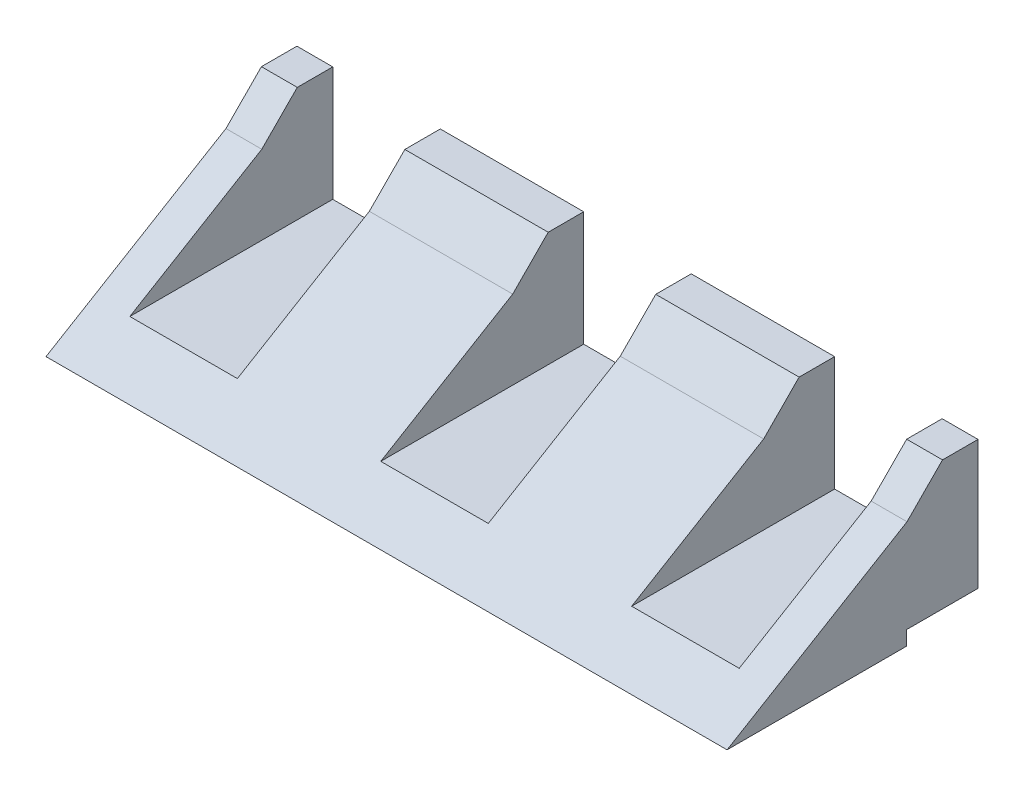
from build123d import *

# Parameters (mm, degrees)
CROQUIS1_W              = 100
CROQUIS1_H              = 85
SALIENTE_EXTRUIR1_DEPTH = 20
CORTAR_EXTRUIR1_REACH   = 102
CORTAR_EXTRUIR2_REACH   = 102
CORTAR_EXTRUIR6_DEPTH   = 5
CROQUIS11_W             = 15
CROQUIS11_H             = 16
CORTAR_EXTRUIR7_DEPTH   = 44
CROQUIS12_W             = 5
CROQUIS12_H             = 49.877192982
CORTAR_EXTRUIR8_DEPTH   = 44
CORTAR_EXTRUIR9_REACH   = 97
CROQUIS13_W             = 50
CROQUIS13_H             = 18
CROQUIS14_W             = 9.804862201
CROQUIS14_H             = 2
CORTAR_EXTRUIR10_DEPTH  = 121
CORTAR_EXTRUIR11_REACH  = 97
CORTAR_EXTRUIR12_REACH  = 97
CORTAR_EXTRUIR13_DEPTH  = 96


with BuildPart() as part:
    # Croquis1 → Saliente-Extruir1 (new body)
    with BuildSketch(Plane(origin=(0, 0, 0), x_dir=(1, 0, 0), z_dir=(0, 1, 0))):
        with Locations((-9.795321637, 18.377192982)):
            Rectangle(CROQUIS1_W, CROQUIS1_H)
    extrude(amount=SALIENTE_EXTRUIR1_DEPTH)

    # Croquis3 → Cortar-Extruir1 (cut, up to next)
    with BuildSketch(Plane(origin=(40.204678363, 0, 0), x_dir=(0, 0, -1), z_dir=(1, 0, 0)), mode=Mode.PRIVATE) as cortar_extruir1_sk1:
        Polygon((-24.122807018, 0), (0.976475977, 20), (-24.122807018, 20), align=None)
    cortar_extruir1_tool1 = extrude(cortar_extruir1_sk1.sketch, amount=-CORTAR_EXTRUIR1_REACH, mode=Mode.PRIVATE) & part.part
    add(cortar_extruir1_tool1.solids().sort_by_distance((40.204678, 13.333333, 15.756379))[0], mode=Mode.SUBTRACT)

    # Croquis4 → Cortar-Extruir2 (cut, up to next)
    with BuildSketch(Plane(origin=(40.204678363, 0, 0), x_dir=(0, 0, -1), z_dir=(1, 0, 0)), mode=Mode.PRIVATE) as cortar_extruir2_sk1:
        Polygon((0.976475977, 20), (0.976475977, 15), (-24.122807018, 0), align=None)
    cortar_extruir2_tool1 = extrude(cortar_extruir2_sk1.sketch, amount=-CORTAR_EXTRUIR2_REACH, mode=Mode.PRIVATE) & part.part
    add(cortar_extruir2_tool1.solids().sort_by_distance((40.204678, 11.666667, 7.389952))[0], mode=Mode.SUBTRACT)

    # Croquis8 → Cortar-Extruir6 (cut)
    with BuildSketch(Plane.ZY.offset(59.795321637)):
        Polygon((-11, 20), (-0.976475977, 20), (-0.976475977, 15), (24.122807018, 0), (-11, 0), align=None)
    extrude(amount=-CORTAR_EXTRUIR6_DEPTH, mode=Mode.SUBTRACT)

    # Croquis11 → Cortar-Extruir7 (cut)
    with BuildSketch(Plane.XY.offset(-11)):
        with Locations((27.704678363, 12)):
            Rectangle(CROQUIS11_W, CROQUIS11_H)
        Polygon((0.204678363, 20), (-14.795321637, 20), (-14.795321637, 4), (0.204678363, 4), (0.204678363, 18.881828366), align=None)
        with Locations((-42.295321637, 12)):
            Rectangle(CROQUIS11_W, CROQUIS11_H)
    extrude(amount=CORTAR_EXTRUIR7_DEPTH, mode=Mode.SUBTRACT)

    # Croquis12 → Cortar-Extruir8 (cut)
    with BuildSketch(Plane(origin=(0, 20, 0), x_dir=(1, 0, 0), z_dir=(0, 1, 0))):
        with Locations((-57.295321637, 35.938596491)):
            Rectangle(CROQUIS12_W, CROQUIS12_H)
    extrude(amount=-CORTAR_EXTRUIR8_DEPTH, mode=Mode.SUBTRACT)

    # Croquis13 → Cortar-Extruir9 (cut, up to next)
    with BuildSketch(Plane(origin=(40.204678363, 0, 0), x_dir=(0, 0, -1), z_dir=(1, 0, 0)), mode=Mode.PRIVATE) as cortar_extruir9_sk1:
        with Locations((35.877192982, 11)):
            Rectangle(CROQUIS13_W, CROQUIS13_H)
    cortar_extruir9_tool1 = extrude(cortar_extruir9_sk1.sketch, amount=-CORTAR_EXTRUIR9_REACH, mode=Mode.PRIVATE) & part.part
    add(cortar_extruir9_tool1.solids().sort_by_distance((40.204678, 11, -35.877193))[0], mode=Mode.SUBTRACT)

    # Croquis14 → Cortar-Extruir10 (cut)
    with BuildSketch(Plane(origin=(40.204678363, 0, 0), x_dir=(0, 0, -1), z_dir=(1, 0, 0))):
        with Locations((5.779624083, 1)):
            Rectangle(CROQUIS14_W, CROQUIS14_H)
    extrude(amount=-CORTAR_EXTRUIR10_DEPTH, mode=Mode.SUBTRACT)

    # Croquis17 → Cortar-Extruir11 (cut, up to next)
    with BuildSketch(Plane(origin=(40.204678363, 0, 0), x_dir=(0, 0, -1), z_dir=(1, 0, 0)), mode=Mode.PRIVATE) as cortar_extruir11_sk1:
        Polygon((10.877192982, 2), (10.682055183, 0), (60.877192982, 0), (60.877192982, 2), align=None)
    cortar_extruir11_tool1 = extrude(cortar_extruir11_sk1.sketch, amount=-CORTAR_EXTRUIR11_REACH, mode=Mode.PRIVATE) & part.part
    add(cortar_extruir11_tool1.solids().sort_by_distance((40.204678, 0.999351, -35.828377))[0], mode=Mode.SUBTRACT)

    # Croquis18 → Cortar-Extruir12 (cut, up to next)
    with BuildSketch(Plane(origin=(40.204678363, 0, 0), x_dir=(0, 0, -1), z_dir=(1, 0, 0)), mode=Mode.PRIVATE) as cortar_extruir12_sk1:
        Polygon((10.682055183, 2), (10.877192982, 2), (10.682055183, 0), align=None)
    cortar_extruir12_tool1 = extrude(cortar_extruir12_sk1.sketch, amount=-CORTAR_EXTRUIR12_REACH, mode=Mode.PRIVATE) & part.part
    add(cortar_extruir12_tool1.solids().sort_by_distance((40.204678, 1.333333, -10.747101))[0], mode=Mode.SUBTRACT)

    # Croquis19 → Cortar-Extruir13 (cut)
    with BuildSketch(Plane.ZY.offset(54.795321637)):
        Polygon((-0.976475977, 15), (-5.92683448, 20), (-0.976475977, 20), align=None)
    extrude(amount=-CORTAR_EXTRUIR13_DEPTH, mode=Mode.SUBTRACT)


solid = part.part
